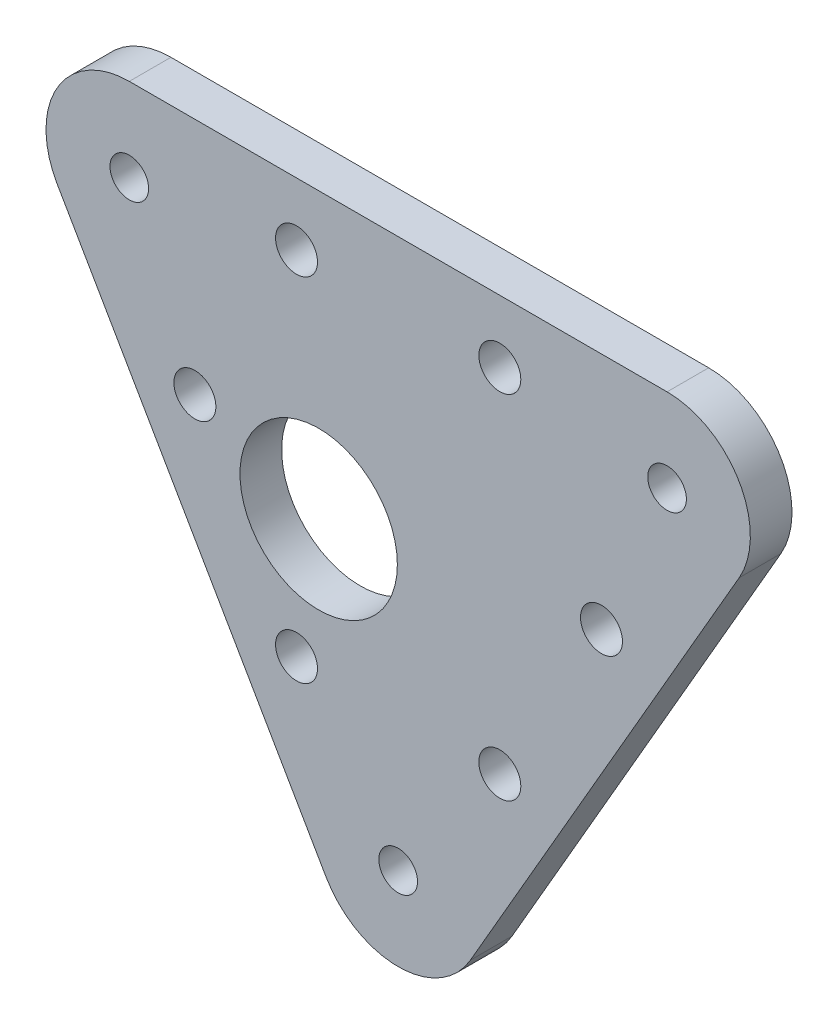
from build123d import *

# Parameters (mm, degrees)
SKETCH1_R                 = 6
BOSS_EXTRUDE1_DEPTH       = 3.175
M3_CLEARANCE_HOLE1_D      = 3.2
FILLET1_R                 = 6.35
F_4_CLEARANCE_HOLE1_D     = 2.9464
F_4_CLEARANCE_HOLE1_DEPTH = 3.302
F_4_CLEARANCE_HOLE1_TIP   = 0.885187864


with BuildPart() as part:
    # Sketch1 → Boss-Extrude1 (new body)
    with BuildSketch(Plane.XY):
        Polygon((-31.498891971, 18.185893759), (0, -36.371787517), (31.498891971, 18.185893759), align=None)
        with Locations((-6.062177826, -3.5)):
            Circle(SKETCH1_R, mode=Mode.SUBTRACT)
    extrude(amount=BOSS_EXTRUDE1_DEPTH)

    # M3 Clearance Hole1 (through all)
    with Locations(Plane(origin=(-27.388360069, 15.242769311, 3.175), x_dir=(1, 0, 0), z_dir=(0, 0, 1))):
        with Locations((19.638360069, -1.819375553), (35.138360069, -1.819375553), (42.888360069, -15.242769311), (11.888360069, -15.242769311), (19.638360069, -28.66616307), (35.138360069, -28.66616307)):
            Hole(M3_CLEARANCE_HOLE1_D / 2)

    # Fillet1
    fillet1_edges = [part.edges().sort_by_distance(p)[0] for p in [
        (31.498891971, 18.185893759, 1.5875),
        (0, -36.371787517, 1.5875),
        (-31.498891971, 18.185893759, 1.5875),
    ]]
    fillet(fillet1_edges, radius=FILLET1_R)

    # #4 Clearance Hole1
    with Locations(Plane(origin=(-21.085137788, 23.004512958, 3.175), x_dir=(1, 0, 0), z_dir=(0, 0, 1))):
        with Locations((0.584768445, -11.1686192), (41.585507131, -11.1686192), (21.085137788, -46.676300475)):
            Hole(F_4_CLEARANCE_HOLE1_D / 2, depth=F_4_CLEARANCE_HOLE1_DEPTH)
            with Locations((0, 0, -(F_4_CLEARANCE_HOLE1_DEPTH + F_4_CLEARANCE_HOLE1_TIP / 2))):  # 118° drill point
                Cone(0, F_4_CLEARANCE_HOLE1_D / 2, F_4_CLEARANCE_HOLE1_TIP, mode=Mode.SUBTRACT)


solid = part.part
